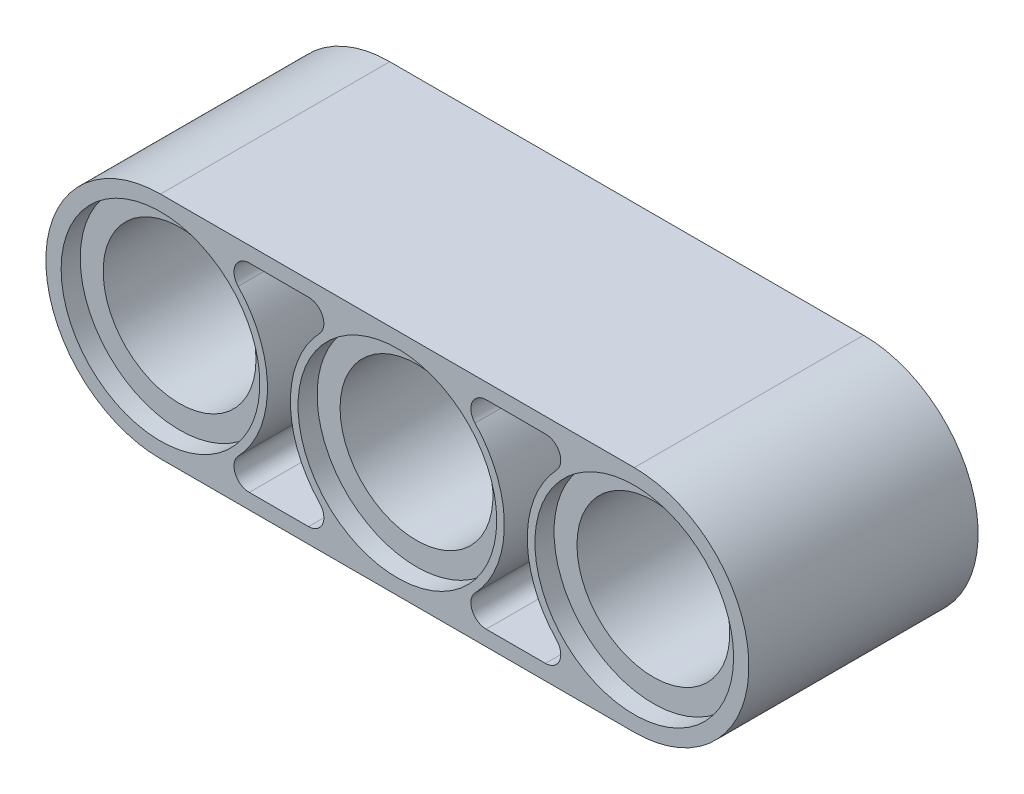
from build123d import *

# Parameters (mm, degrees)
SKETCH1_R           = 2.54
BOSS_EXTRUDE1_DEPTH = 3.81
SKETCH1_7_R         = 2.54
BOSS_EXTRUDE2_DEPTH = 3.81
SKETCH2_R           = 3.302
CUT_EXTRUDE1_DEPTH  = 0.635


with BuildPart() as part:
    # Sketch1 → Boss-Extrude1 (new body)
    with BuildSketch(Plane.XY):
        with BuildLine():
            Line((3.937, -3.81), (7.874, -3.81))
            ThreePointArc((7.874, -3.81), (11.684, 0), (7.874, 3.81))
            Line((7.874, 3.81), (3.937, 3.81))
            Line((3.937, 3.81), (3.937, 3.302))
            Line((3.937, 3.302), (4.92278669, 3.302))
            ThreePointArc((4.92278669, 3.302), (5.389414486, 2.994804631), (5.291688354, 2.44475))
            ThreePointArc((5.291688354, 2.44475), (4.318, 0), (5.291688354, -2.44475))
            ThreePointArc((5.291688354, -2.44475), (5.389414486, -2.994804631), (4.92278669, -3.302))
            Line((4.92278669, -3.302), (3.937, -3.302))
            Line((3.937, -3.302), (3.937, -3.81))
        make_face()
        with Locations((7.874, 0)):
            Circle(SKETCH1_R, mode=Mode.SUBTRACT)
    extrude(amount=BOSS_EXTRUDE1_DEPTH)


with BuildPart() as body_2:
    # Sketch1_7 → Boss-Extrude2 (new body)
    with BuildSketch(Plane.XY):
        with BuildLine():
            Line((3.937, -3.81), (3.937, -3.302))
            Line((3.937, -3.302), (2.95121331, -3.302))
            ThreePointArc((2.95121331, -3.302), (2.484585514, -2.994804631), (2.582311646, -2.44475))
            ThreePointArc((2.582311646, -2.44475), (3.556, 0), (2.582311646, 2.44475))
            ThreePointArc((2.582311646, 2.44475), (2.484585514, 2.994804631), (2.95121331, 3.302))
            Line((2.95121331, 3.302), (3.937, 3.302))
            Line((3.937, 3.302), (3.937, 3.81))
            Line((3.937, 3.81), (-3.937, 3.81))
            Line((-3.937, 3.81), (-3.937, 3.302))
            Line((-3.937, 3.302), (-2.95121331, 3.302))
            ThreePointArc((-2.95121331, 3.302), (-2.484585514, 2.994804631), (-2.582311646, 2.44475))
            ThreePointArc((-2.582311646, 2.44475), (-3.556, 0), (-2.582311646, -2.44475))
            ThreePointArc((-2.582311646, -2.44475), (-2.484585514, -2.994804631), (-2.95121331, -3.302))
            Line((-2.95121331, -3.302), (-3.937, -3.302))
            Line((-3.937, -3.302), (-3.937, -3.81))
            Line((-3.937, -3.81), (3.937, -3.81))
        make_face()
        Circle(SKETCH1_7_R, mode=Mode.SUBTRACT)
    extrude(amount=BOSS_EXTRUDE2_DEPTH)


with BuildPart() as cut_extrude1_tool:
    # Sketch2 → Cut-Extrude1 (new body)
    with BuildSketch(Plane.XY):
        with Locations((7.874, 0)):
            Circle(SKETCH2_R)
        Circle(SKETCH2_R)
    extrude(amount=CUT_EXTRUDE1_DEPTH)


with BuildPart() as part_1:
    add(part.part)

    # Cut-Extrude1: cut by cut_extrude1_tool
    add(cut_extrude1_tool.part, mode=Mode.SUBTRACT)


with BuildPart() as body_2_1:
    add(body_2.part)

    # Cut-Extrude1: cut by cut_extrude1_tool
    add(cut_extrude1_tool.part, mode=Mode.SUBTRACT)


with BuildPart() as body_3:
    # Mirror2: mirrored copy
    add(part_1.part.mirror(Plane(origin=(0, 0, 0), x_dir=(0, 0, 1), z_dir=(1, 0, 0))))


with BuildPart() as part_2:
    add(part_1.part)

    # Combine1: union body 3, body 2
    add(body_3.part)
    add(body_2_1.part)

    # Mirror3: part across plane


with BuildPart() as part_3:
    add(part_2.part)
    add(part_2.part.mirror(Plane.XY.offset(3.81)))


solid = part_3.part
